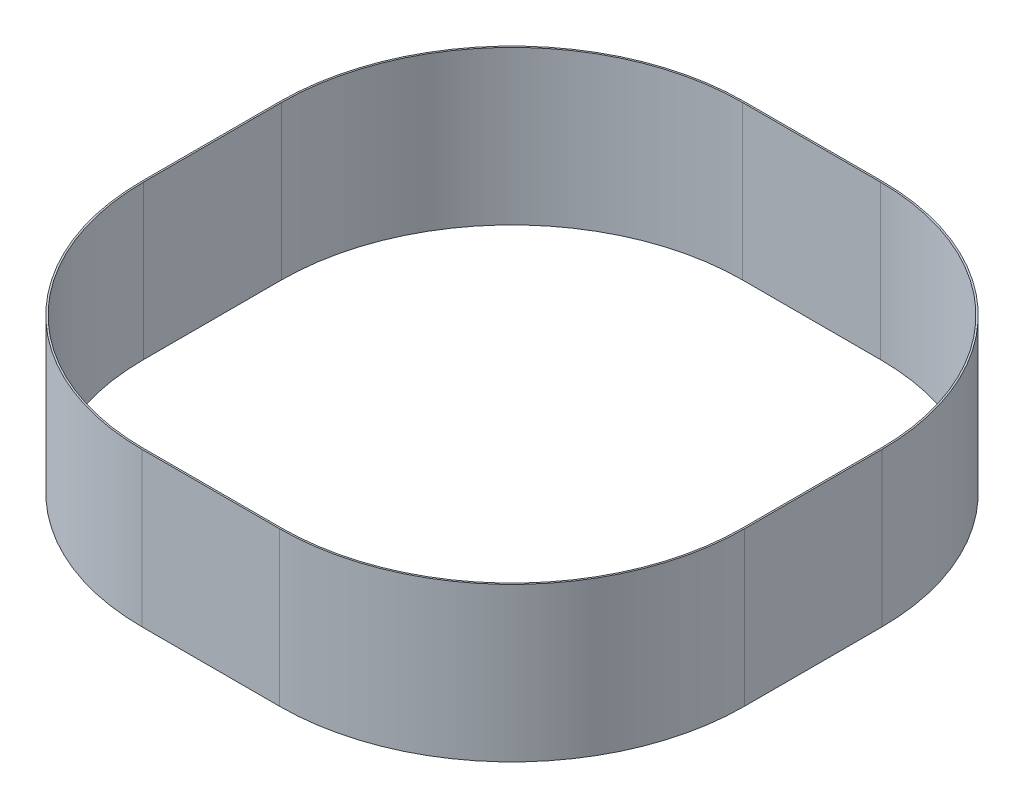
from build123d import *

# Parameters (mm, degrees)
BOSS_EXTRUDE1_DEPTH = 76.2


with BuildPart() as part:
    # Sketch1 → Boss-Extrude1 (new body)
    with BuildSketch(Plane(origin=(0, 0, 0), x_dir=(1, 0, 0), z_dir=(0, 1, 0))):
        with BuildLine():
            Line((-34.13125, 149.225), (34.13125, 149.225))
            ThreePointArc((34.13125, 149.225), (115.514821097, 115.514821097), (149.225, 34.13125))
            Line((149.225, 34.13125), (149.225, -34.13125))
            ThreePointArc((149.225, -34.13125), (115.514821097, -115.514821097), (34.13125, -149.225))
            Line((34.13125, -149.225), (-34.13125, -149.225))
            ThreePointArc((-34.13125, -149.225), (-115.514821097, -115.514821097), (-149.225, -34.13125))
            Line((-149.225, -34.13125), (-149.225, 34.13125))
            ThreePointArc((-149.225, 34.13125), (-115.514821097, 115.514821097), (-34.13125, 149.225))
        make_face()
        with BuildLine():
            Line((-34.13125, -148.43125), (34.13125, -148.43125))
            ThreePointArc((34.13125, -148.43125), (114.95355509, -114.95355509), (148.43125, -34.13125))
            Line((148.43125, -34.13125), (148.43125, 34.13125))
            ThreePointArc((148.43125, 34.13125), (114.95355509, 114.95355509), (34.13125, 148.43125))
            Line((34.13125, 148.43125), (-34.13125, 148.43125))
            ThreePointArc((-34.13125, 148.43125), (-114.95355509, 114.95355509), (-148.43125, 34.13125))
            Line((-148.43125, 34.13125), (-148.43125, -34.13125))
            ThreePointArc((-148.43125, -34.13125), (-114.95355509, -114.95355509), (-34.13125, -148.43125))
        make_face(mode=Mode.SUBTRACT)
    extrude(amount=BOSS_EXTRUDE1_DEPTH)


solid = part.part
